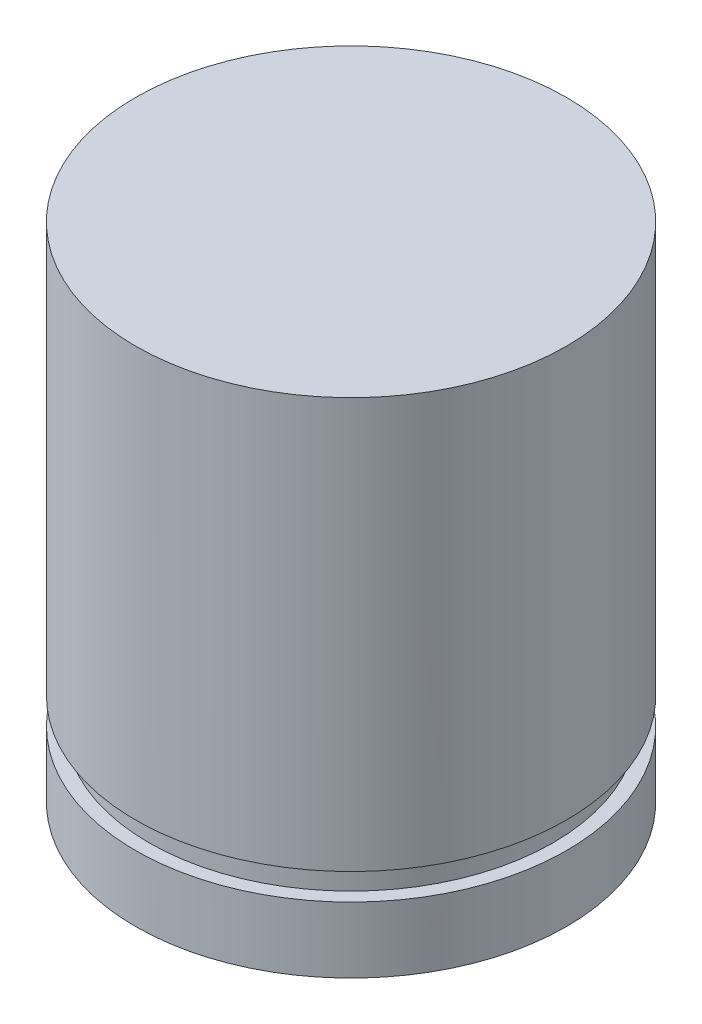
from build123d import *

# Parameters (mm, degrees)
SKETCH1_R           = 6
BOSS_EXTRUDE1_DEPTH = 14
SKETCH2_R           = 5.6261
CUT_EXTRUDE1_DEPTH  = 0.7366


with BuildPart() as part:
    # Sketch1 → Boss-Extrude1 (new body)
    with BuildSketch(Plane(origin=(0, 0, 0), x_dir=(1, 0, 0), z_dir=(0, 1, 0))):
        Circle(SKETCH1_R)
    extrude(amount=BOSS_EXTRUDE1_DEPTH)

    # Sketch2 → Cut-Extrude1 (cut)
    with BuildSketch(Plane(origin=(0, 2.57, 0), x_dir=(1, 0, 0), z_dir=(0, 1, 0))):
        Polygon((-7.915464339, 6.772300258), (-7.748596028, -7.998854616), (10.395730316, -7.998854616), (9.153265383, 7.840750397), align=None)
        Circle(SKETCH2_R, mode=Mode.SUBTRACT)
    extrude(amount=-CUT_EXTRUDE1_DEPTH, mode=Mode.SUBTRACT)


solid = part.part
